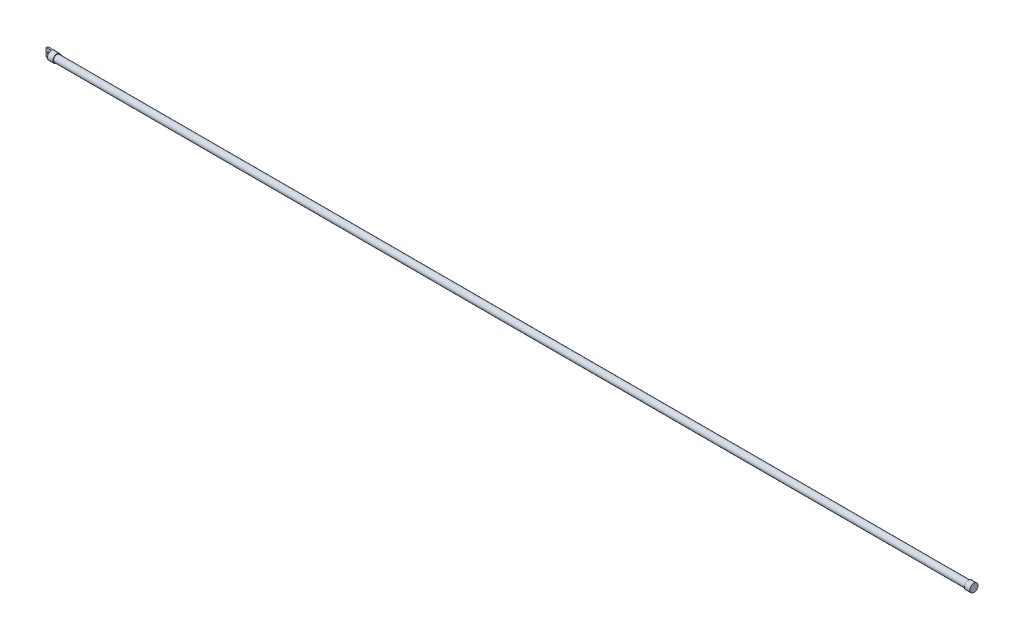
from build123d import *

# Parameters (mm, degrees)
SKETCH1_R           = 15.875
BOSS_EXTRUDE1_DEPTH = 4267.2
SKETCH2_R           = 19.05
BOSS_EXTRUDE2_DEPTH = 25.4
SKETCH3_R           = 19.05
BOSS_EXTRUDE3_DEPTH = 50.8
SKETCH4_W           = 29.09743832
SKETCH4_H           = 50.636173691
CUT_EXTRUDE1_DEPTH  = 25.4
SKETCH5_R           = 6.35
CUT_EXTRUDE2_DEPTH  = 20.05


with BuildPart() as part:
    # Sketch1 → Boss-Extrude1 (new body)
    with BuildSketch(Plane(origin=(0, 0, 0), x_dir=(0, 0, -1), z_dir=(1, 0, 0))):
        Circle(SKETCH1_R)
    extrude(amount=BOSS_EXTRUDE1_DEPTH)

    # Sketch2 → Boss-Extrude2 (add)
    with BuildSketch(Plane(origin=(4267.2, 0, 0), x_dir=(0, 0, -1), z_dir=(1, 0, 0))):
        Circle(SKETCH2_R)
    extrude(amount=-BOSS_EXTRUDE2_DEPTH)

    # Sketch3 → Boss-Extrude3 (add)
    with BuildSketch(Plane.ZY):
        Circle(SKETCH3_R)
    extrude(amount=BOSS_EXTRUDE3_DEPTH)

    # Sketch4 → Cut-Extrude1 (cut)
    with BuildSketch(Plane.ZY.offset(50.8)):
        with Locations((14.54871916, 1.209789986)):
            Rectangle(SKETCH4_W, SKETCH4_H)
    extrude(amount=-CUT_EXTRUDE1_DEPTH, mode=Mode.SUBTRACT)

    # Sketch5 → Cut-Extrude2 (cut, through all)
    with BuildSketch(Plane.XY):
        with Locations((-38.1, 0)):
            Circle(SKETCH5_R)
    extrude(amount=-CUT_EXTRUDE2_DEPTH, mode=Mode.SUBTRACT)


solid = part.part
